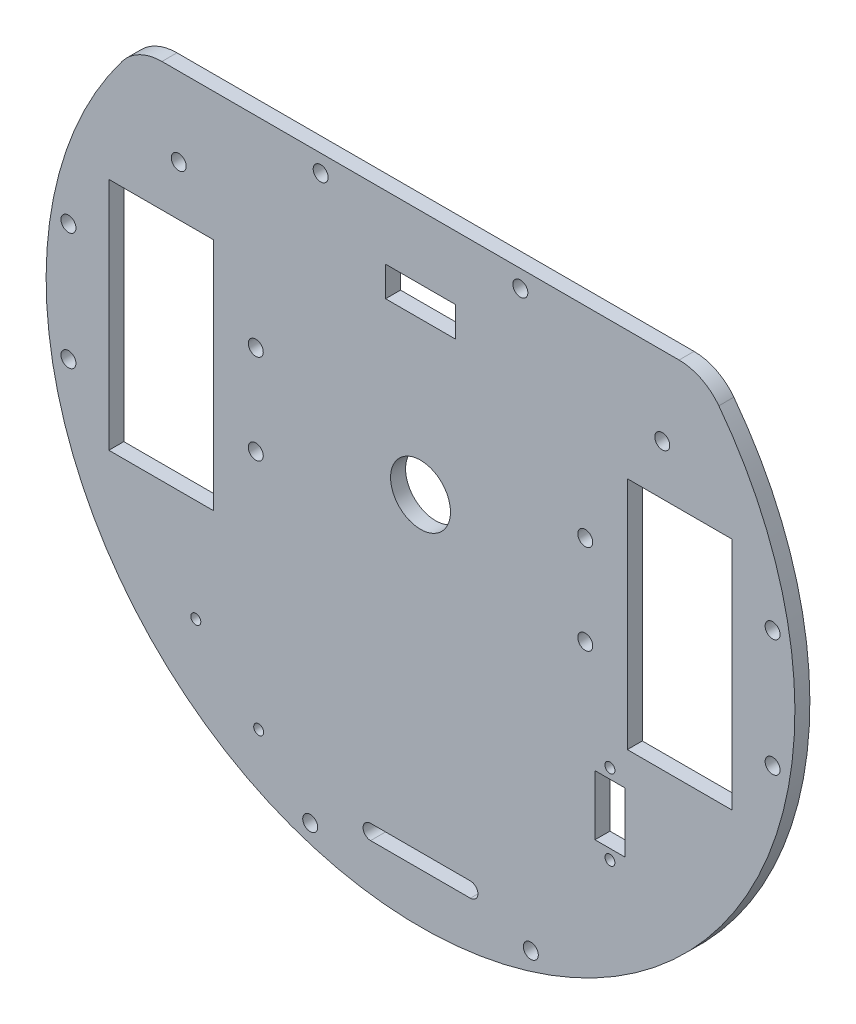
from build123d import *

# Parameters (mm, degrees)
SKETCH1_R           = 1.5
SKETCH1_R_2         = 6
SKETCH1_R_3         = 1
SKETCH1_W           = 21
SKETCH1_H           = 47
SKETCH1_W_2         = 6
SKETCH1_H_2         = 12
SKETCH1_W_3         = 14
SKETCH1_H_3         = 6
BOSS_EXTRUDE2_DEPTH = 3


with BuildPart() as part:
    # Sketch1 → Boss-Extrude2 (new body)
    with BuildSketch(Plane.XY):
        with BuildLine():
            Line((-51.796300436, 49.270131922), (51.796300436, 49.270131922))
            ThreePointArc((51.796300436, 49.270131922), (56.24514368, 48.226012325), (59.764962041, 45.311690679))
            ThreePointArc((59.764962041, 45.311690679), (0, -75), (-59.764962041, 45.311690679))
            ThreePointArc((-59.764962041, 45.311690679), (-56.24514368, 48.226012325), (-51.796300436, 49.270131922))
        make_face()
        with Locations((22.094715098, -68.059231897)):
            Circle(SKETCH1_R, mode=Mode.SUBTRACT)
        with Locations((-22.094715098, -68.000540915)):
            Circle(SKETCH1_R, mode=Mode.SUBTRACT)
        Circle(SKETCH1_R_2, mode=Mode.SUBTRACT)
        with Locations((-33, 9)):
            Circle(SKETCH1_R, mode=Mode.SUBTRACT)
        with Locations((-33, -9)):
            Circle(SKETCH1_R, mode=Mode.SUBTRACT)
        with Locations((48.430328075, 33.5)):
            Circle(SKETCH1_R, mode=Mode.SUBTRACT)
        with Locations((20, 45.770131922)):
            Circle(SKETCH1_R, mode=Mode.SUBTRACT)
        with Locations((-20, 45.770131922)):
            Circle(SKETCH1_R, mode=Mode.SUBTRACT)
        with Locations((-48.430328075, 33.5)):
            Circle(SKETCH1_R, mode=Mode.SUBTRACT)
        with Locations((-32.419192278, -56.938528011)):
            Circle(SKETCH1_R_3, mode=Mode.SUBTRACT)
        with Locations((-45.012826675, -44.077720389)):
            Circle(SKETCH1_R_3, mode=Mode.SUBTRACT)
        with Locations((37.944032627, -28.385695159)):
            Circle(SKETCH1_R_3, mode=Mode.SUBTRACT)
        with Locations((37.944032627, -44.385695159)):
            Circle(SKETCH1_R_3, mode=Mode.SUBTRACT)
        with Locations((-70.527920003, 11.75)):
            Circle(SKETCH1_R, mode=Mode.SUBTRACT)
        with Locations((-70.527920003, -11.75)):
            Circle(SKETCH1_R, mode=Mode.SUBTRACT)
        with Locations((70.527920003, -11.75)):
            Circle(SKETCH1_R, mode=Mode.SUBTRACT)
        with Locations((70.527920003, 11.75)):
            Circle(SKETCH1_R, mode=Mode.SUBTRACT)
        with Locations((33, -9)):
            Circle(SKETCH1_R, mode=Mode.SUBTRACT)
        with Locations((33, 9)):
            Circle(SKETCH1_R, mode=Mode.SUBTRACT)
        with Locations((-51.930328075, 0)):
            Rectangle(SKETCH1_W, SKETCH1_H, mode=Mode.SUBTRACT)
        with BuildLine():
            Line((-10, -62), (10, -62))
            ThreePointArc((10, -62), (11.5, -63.5), (10, -65))
            Line((10, -65), (-10, -65))
            ThreePointArc((-10, -65), (-11.5, -63.5), (-10, -62))
        make_face(mode=Mode.SUBTRACT)
        with Locations((37.944032627, -36.385695159)):
            Rectangle(SKETCH1_W_2, SKETCH1_H_2, mode=Mode.SUBTRACT)
        with Locations((51.930328075, 0)):
            Rectangle(SKETCH1_W, SKETCH1_H, mode=Mode.SUBTRACT)
        with Locations((0, 33.5)):
            Rectangle(SKETCH1_W_3, SKETCH1_H_3, mode=Mode.SUBTRACT)
    extrude(amount=BOSS_EXTRUDE2_DEPTH)


solid = part.part
